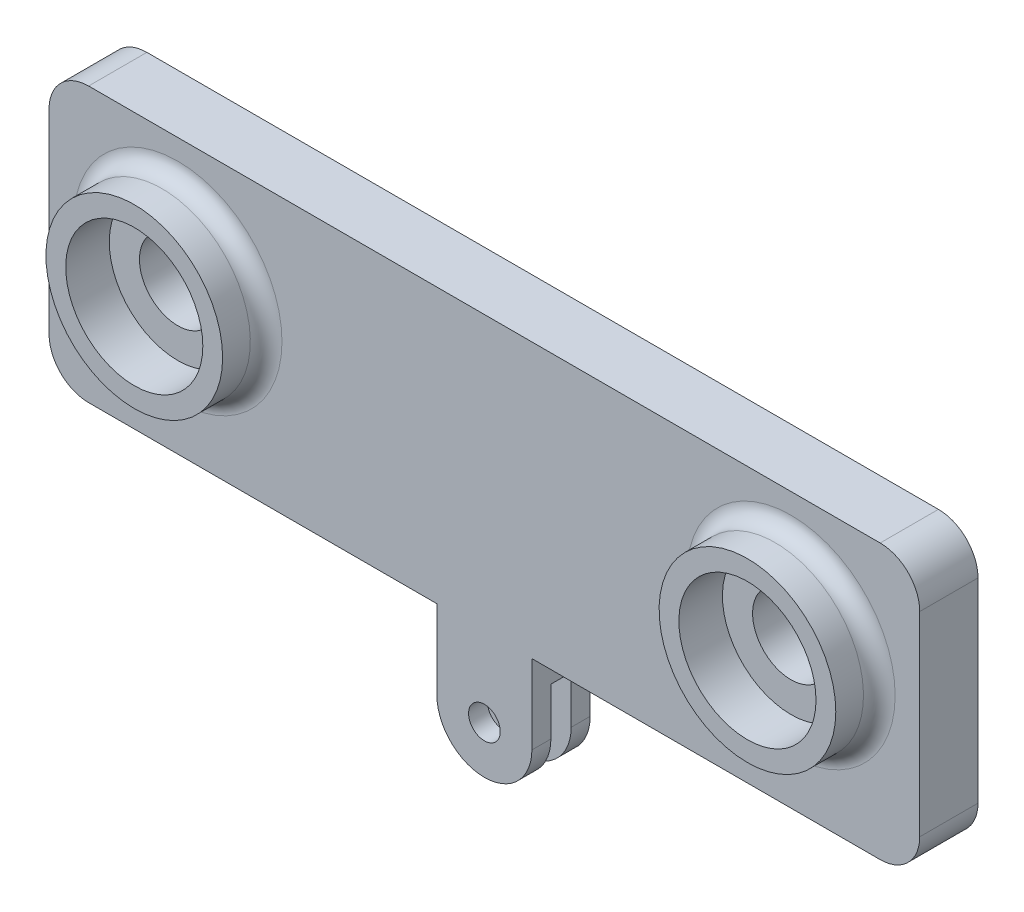
from build123d import *

# Parameters (mm, degrees)
BOSS_EXTRUDE1_DEPTH = 15.24
CUT_EXTRUDE1_DEPTH  = 24.492240162
SKETCH3_W           = 139.7
SKETCH3_H           = 44
BOSS_EXTRUDE2_DEPTH = 9.3472
FILLET1_R           = 6.35
SKETCH6_R           = 6.1595
CUT_EXTRUDE2_DEPTH  = 93.183607262
SKETCH7_R           = 0.9652
CUT_EXTRUDE3_DEPTH  = 5.588
SKETCH8_R           = 0.80645
CUT_EXTRUDE4_DEPTH  = 5.08
SKETCH9_R           = 14.175
SKETCH9_R_2         = 11
BOSS_EXTRUDE5_DEPTH = 6.985
FILLET2_R           = 2.54


with BuildPart() as part:
    # Sketch1 → Boss-Extrude1 (new body)
    with BuildSketch(Plane(origin=(0, 0, 0), x_dir=(0, 0, -1), z_dir=(1, 0, 0))):
        Polygon((-4.6736, 0), (-4.6736, 5.08), (4.6736, 5.08), (4.6736, 0), (4.6736, -15.24), (1.6256, -15.24), (1.6256, 0), (-1.6256, 0), (-1.6256, -15.24), (-4.6736, -15.24), align=None)
    extrude(amount=-BOSS_EXTRUDE1_DEPTH)

    # Sketch2 → Cut-Extrude1 (cut, through all)
    with BuildSketch(Plane.XY.offset(4.6736)):
        with BuildLine():
            ThreePointArc((-5.08, -7.62), (-5.823948776, -5.823948776), (-7.62, -5.08))
            Line((-7.62, -5.08), (-7.62, -10.16))
            ThreePointArc((-7.62, -10.16), (-5.823948776, -9.416051224), (-5.08, -7.62))
        make_face()
        with BuildLine():
            Line((-7.62, -10.16), (-7.62, -5.08))
            ThreePointArc((-7.62, -5.08), (-10.16, -7.62), (-7.62, -10.16))
        make_face()
        with BuildLine():
            ThreePointArc((-7.62, -15.24), (-13.008153673, -13.008153673), (-15.24, -7.62))
            Line((-15.24, -7.62), (-15.24, -15.24))
            Line((-15.24, -15.24), (-7.62, -15.24))
        make_face()
        with BuildLine():
            Line((0, -15.24), (0, -7.62))
            ThreePointArc((0, -7.62), (-2.231846327, -13.008153673), (-7.62, -15.24))
            Line((-7.62, -15.24), (0, -15.24))
        make_face()
    extrude(amount=-CUT_EXTRUDE1_DEPTH, mode=Mode.SUBTRACT)

    # Sketch3 → Boss-Extrude2 (add)
    with BuildSketch(Plane.XY.offset(4.6736)):
        with Locations((-7.62, 27.08)):
            Rectangle(SKETCH3_W, SKETCH3_H)
    extrude(amount=-BOSS_EXTRUDE2_DEPTH)

    # Fillet1
    fillet1_edges = [part.edges().sort_by_distance(p)[0] for p in [
        (62.23, 5.08, 0),
        (62.23, 49.08, 0),
        (-77.47, 49.08, 0),
        (-77.47, 5.08, 0),
    ]]
    fillet(fillet1_edges, radius=FILLET1_R)

    # Sketch6 → Cut-Extrude2 (cut, through all)
    with BuildSketch(Plane.XY.offset(4.6736)):
        with Locations((-56.809999918, 29.08)):
            Circle(SKETCH6_R)
        with Locations((41.569999918, 29.08)):
            Circle(SKETCH6_R)
    extrude(amount=-CUT_EXTRUDE2_DEPTH, mode=Mode.SUBTRACT)

    # Sketch7 → Cut-Extrude3 (cut)
    with BuildSketch(Plane(origin=(0, 0, -4.6736), x_dir=(-1, 0, 0), z_dir=(0, 0, -1))):
        with Locations((30.48, 35.97)):
            Circle(SKETCH7_R)
        with Locations((-15.24, 35.97)):
            Circle(SKETCH7_R)
        with Locations((30.48, 18.19)):
            Circle(SKETCH7_R)
        with Locations((-15.24, 18.19)):
            Circle(SKETCH7_R)
        with Locations((7.62, 7.649)):
            Circle(SKETCH7_R)
        with Locations((7.62, 46.511)):
            Circle(SKETCH7_R)
    extrude(amount=-CUT_EXTRUDE3_DEPTH, mode=Mode.SUBTRACT)

    # Sketch8 → Cut-Extrude4 (cut)
    with BuildSketch(Plane(origin=(0, 0, -4.6736), x_dir=(-1, 0, 0), z_dir=(0, 0, -1))):
        with Locations((-41.57, 37.83)):
            Circle(SKETCH8_R)
        with Locations((-41.57, 9.83)):
            Circle(SKETCH8_R)
        with Locations((56.81, 37.83)):
            Circle(SKETCH8_R)
        with Locations((56.81, 9.83)):
            Circle(SKETCH8_R)
    extrude(amount=-CUT_EXTRUDE4_DEPTH, mode=Mode.SUBTRACT)

    # Sketch9 → Boss-Extrude5 (add)
    with BuildSketch(Plane.XY.offset(4.6736)):
        with Locations((-56.81, 29.08)):
            Circle(SKETCH9_R)
        with Locations(Location((-56.81, 29.08, 0), (0, 0, 270))):
            Circle(SKETCH9_R_2, mode=Mode.SUBTRACT)
        with Locations((41.57, 29.08)):
            Circle(SKETCH9_R)
        with Locations(Location((41.57, 29.08, 0), (0, 0, 270))):
            Circle(SKETCH9_R_2, mode=Mode.SUBTRACT)
    extrude(amount=BOSS_EXTRUDE5_DEPTH)

    # Fillet2
    fillet2_edges = [part.edges().sort_by_distance(p)[0] for p in [
        (-70.985, 29.08, 4.6736),
        (27.395, 29.08, 4.6736),
    ]]
    fillet(fillet2_edges, radius=FILLET2_R)


solid = part.part
